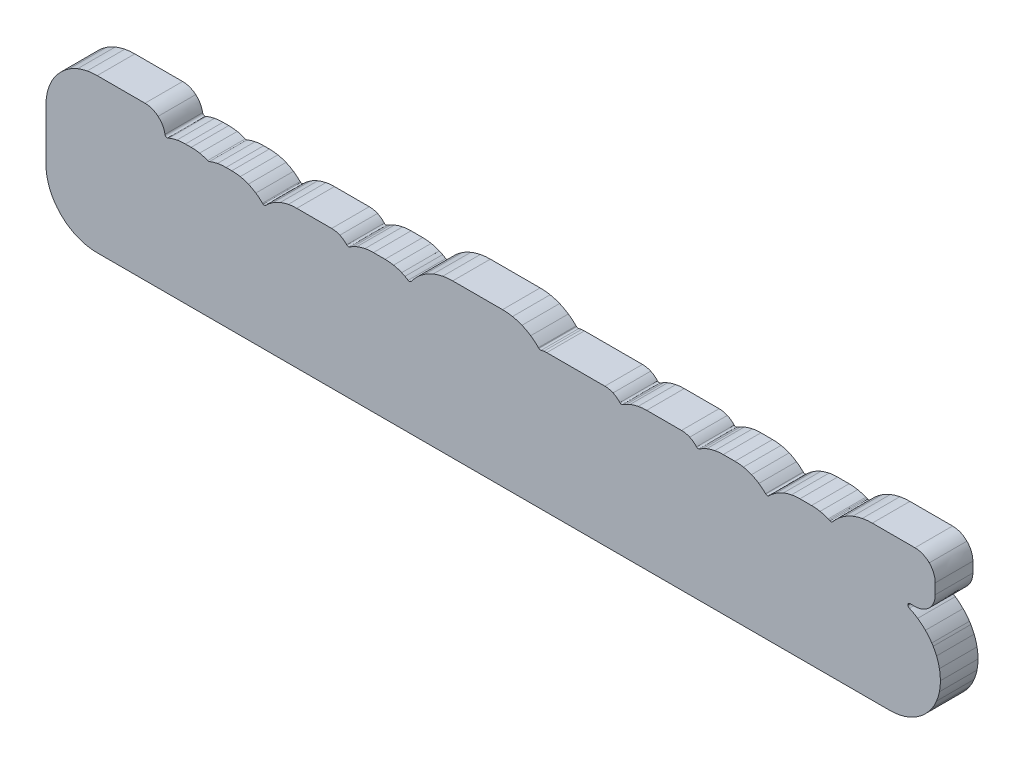
from build123d import *

# Parameters (mm, degrees)
RESSALTO_EXTRUS_O2_DEPTH = 30


with BuildPart() as part:
    # Esboço1 → Ressalto-extrusão2 (new body)
    with BuildSketch(Plane.XY):
        with BuildLine():
            Line((-356.462584, 0.418338), (-356.462584, 20.524216))
            add(Edge.make_bspline(
                [(-356.462584, 20.524216), (-356.462584, 23.265384), (-356.207568, 25.931622), (-355.698044, 28.52166)],
                knots=[0.015384615, 0.015384615, 0.015384615, 0.015384615, 0.023076923, 0.023076923, 0.023076923, 0.023076923], degree=3))
            add(Edge.make_bspline(
                [(-355.698044, 28.52166), (-355.187504, 31.11627), (-354.422456, 33.640776), (-353.404678, 36.092638)],
                knots=[0.023076923, 0.023076923, 0.023076923, 0.023076923, 0.030769231, 0.030769231, 0.030769231, 0.030769231], degree=3))
            add(Edge.make_bspline(
                [(-353.404678, 36.092638), (-352.383852, 38.551104), (-351.136966, 40.874188), (-349.666052, 43.059858)],
                knots=[0.030769231, 0.030769231, 0.030769231, 0.030769231, 0.038461538, 0.038461538, 0.038461538, 0.038461538], degree=3))
            add(Edge.make_bspline(
                [(-349.666052, 43.059858), (-348.202504, 45.23486), (-346.49537, 47.297848), (-344.545412, 49.247552)],
                knots=[0.038461538, 0.038461538, 0.038461538, 0.038461538, 0.046153846, 0.046153846, 0.046153846, 0.046153846], degree=3))
            add(Edge.make_bspline(
                [(-344.545412, 49.247552), (-342.608154, 51.18481), (-340.540848, 52.887626), (-338.346034, 54.352952)],
                knots=[0.046153846, 0.046153846, 0.046153846, 0.046153846, 0.053846154, 0.053846154, 0.053846154, 0.053846154], degree=3))
            add(Edge.make_bspline(
                [(-338.346034, 54.352952), (-336.138266, 55.827168), (-333.785972, 57.078626), (-331.29093, 58.10631)],
                knots=[0.053846154, 0.053846154, 0.053846154, 0.053846154, 0.061538462, 0.061538462, 0.061538462, 0.061538462], degree=3))
            add(Edge.make_bspline(
                [(-331.29093, 58.10631), (-328.822558, 59.12231), (-326.28205, 59.887104), (-323.669914, 60.39993)],
                knots=[0.061538462, 0.061538462, 0.061538462, 0.061538462, 0.069230769, 0.069230769, 0.069230769, 0.069230769], degree=3))
            add(Edge.make_bspline(
                [(-323.669914, 60.39993), (-321.074034, 60.9092), (-318.408812, 61.164216), (-315.676534, 61.164216)],
                knots=[0.069230769, 0.069230769, 0.069230769, 0.069230769, 0.076923077, 0.076923077, 0.076923077, 0.076923077], degree=3))
            Line((-315.676534, 61.164216), (-277.5585, 61.164216))
            add(Edge.make_bspline(
                [(-277.5585, 61.164216), (-273.569938, 61.164216), (-269.919958, 59.721496), (-267.104114, 57.33161)],
                knots=[0.084615385, 0.084615385, 0.084615385, 0.084615385, 0.092307692, 0.092307692, 0.092307692, 0.092307692], degree=3))
            add(Edge.make_bspline(
                [(-267.104114, 57.33161), (-264.243566, 54.903116), (-262.238744, 51.496468), (-261.608824, 47.631604)],
                knots=[0.092307692, 0.092307692, 0.092307692, 0.092307692, 0.1, 0.1, 0.1, 0.1], degree=3))
            add(Edge.make_bspline(
                [(-261.608824, 47.631604), (-261.450074, 46.655736), (-260.529832, 45.993304), (-259.553964, 46.1518)],
                knots=[0.1, 0.1, 0.1, 0.1, 0.107692308, 0.107692308, 0.107692308, 0.107692308], degree=3))
            add(Edge.make_bspline(
                [(-259.553964, 46.1518), (-259.377688, 46.180756), (-259.211826, 46.234604), (-259.059172, 46.308518)],
                knots=[0.107692308, 0.107692308, 0.107692308, 0.107692308, 0.115384615, 0.115384615, 0.115384615, 0.115384615], degree=3))
            Line((-259.059172, 46.308518), (-258.606036, 46.499272))
            add(Edge.make_bspline(
                [(-258.606036, 46.499272), (-256.500376, 47.367952), (-254.33782, 48.021748), (-252.121162, 48.460152)],
                knots=[0.130769231, 0.130769231, 0.130769231, 0.130769231, 0.138461538, 0.138461538, 0.138461538, 0.138461538], degree=3))
            add(Edge.make_bspline(
                [(-252.121162, 48.460152), (-249.917966, 48.895762), (-247.661684, 49.113948), (-245.35384, 49.113948)],
                knots=[0.138461538, 0.138461538, 0.138461538, 0.138461538, 0.146153846, 0.146153846, 0.146153846, 0.146153846], degree=3))
            Line((-245.35384, 49.113948), (-240.773966, 49.113948))
            add(Edge.make_bspline(
                [(-240.773966, 49.113948), (-238.46282, 49.113948), (-236.21111, 48.899318), (-234.019852, 48.470566)],
                knots=[0.153846154, 0.153846154, 0.153846154, 0.153846154, 0.161538462, 0.161538462, 0.161538462, 0.161538462], degree=3))
            add(Edge.make_bspline(
                [(-234.019852, 48.470566), (-231.811068, 48.038766), (-229.664768, 47.394622), (-227.584508, 46.54042)],
                knots=[0.161538462, 0.161538462, 0.161538462, 0.161538462, 0.169230769, 0.169230769, 0.169230769, 0.169230769], degree=3))
            add(Edge.make_bspline(
                [(-227.584508, 46.54042), (-227.13061, 46.353984), (-226.644708, 46.3677), (-226.22383, 46.54042)],
                knots=[0.169230769, 0.169230769, 0.169230769, 0.169230769, 0.176923077, 0.176923077, 0.176923077, 0.176923077], degree=3))
            add(Edge.make_bspline(
                [(-226.22383, 46.54042), (-224.150682, 47.3964), (-222.009462, 48.040544), (-219.801694, 48.470566)],
                knots=[0.176923077, 0.176923077, 0.176923077, 0.176923077, 0.184615385, 0.184615385, 0.184615385, 0.184615385], degree=3))
            add(Edge.make_bspline(
                [(-219.801694, 48.470566), (-217.602308, 48.899318), (-215.3285, 49.113948), (-212.983064, 49.113948)],
                knots=[0.184615385, 0.184615385, 0.184615385, 0.184615385, 0.192307692, 0.192307692, 0.192307692, 0.192307692], degree=3))
            Line((-212.983064, 49.113948), (-208.402936, 49.113948))
            add(Edge.make_bspline(
                [(-208.402936, 49.113948), (-206.094838, 49.113948), (-203.83881, 48.895762), (-201.63536, 48.460152)],
                knots=[0.2, 0.2, 0.2, 0.2, 0.207692308, 0.207692308, 0.207692308, 0.207692308], degree=3))
            add(Edge.make_bspline(
                [(-201.63536, 48.460152), (-199.418702, 48.021748), (-197.256654, 47.367698), (-195.151248, 46.498764)],
                knots=[0.207692308, 0.207692308, 0.207692308, 0.207692308, 0.215384615, 0.215384615, 0.215384615, 0.215384615], degree=3))
            add(Edge.make_bspline(
                [(-195.151248, 46.498764), (-193.063368, 45.636942), (-191.080644, 44.57573), (-189.204854, 43.316398)],
                knots=[0.215384615, 0.215384615, 0.215384615, 0.215384615, 0.223076923, 0.223076923, 0.223076923, 0.223076923], degree=3))
            add(Edge.make_bspline(
                [(-189.204854, 43.316398), (-187.331096, 42.057828), (-185.560462, 40.596566), (-183.892952, 38.932866)],
                knots=[0.223076923, 0.223076923, 0.223076923, 0.223076923, 0.230769231, 0.230769231, 0.230769231, 0.230769231], degree=3))
            add(Edge.make_bspline(
                [(-183.892952, 38.932866), (-183.740044, 38.780974), (-183.566562, 38.662102), (-183.38165, 38.576758)],
                knots=[0.230769231, 0.230769231, 0.230769231, 0.230769231, 0.238461538, 0.238461538, 0.238461538, 0.238461538], degree=3))
            add(Edge.make_bspline(
                [(-183.38165, 38.576758), (-182.698644, 38.181026), (-181.809136, 38.274244), (-181.222904, 38.857428)],
                knots=[0.238461538, 0.238461538, 0.238461538, 0.238461538, 0.246153846, 0.246153846, 0.246153846, 0.246153846], degree=3))
            Line((-181.222904, 38.857428), (-181.216046, 38.864286))
            Line((-181.216046, 38.864286), (-181.109112, 38.97122))
            Line((-181.109112, 38.97122), (-181.10581, 38.967918))
            add(Edge.make_bspline(
                [(-181.10581, 38.967918), (-179.469796, 40.604186), (-177.717196, 42.044874), (-175.850296, 43.289474)],
                knots=[0.269230769, 0.269230769, 0.269230769, 0.269230769, 0.276923077, 0.276923077, 0.276923077, 0.276923077], degree=3))
            Line((-175.850296, 43.289474), (-175.784002, 43.335702))
            add(Edge.make_bspline(
                [(-175.784002, 43.335702), (-173.921674, 44.572174), (-171.932092, 45.626782), (-169.818558, 46.498764)],
                knots=[0.284615385, 0.284615385, 0.284615385, 0.284615385, 0.292307692, 0.292307692, 0.292307692, 0.292307692], degree=3))
            add(Edge.make_bspline(
                [(-169.818558, 46.498764), (-167.712898, 47.367698), (-165.55085, 48.021748), (-163.333938, 48.460152)],
                knots=[0.292307692, 0.292307692, 0.292307692, 0.292307692, 0.3, 0.3, 0.3, 0.3], degree=3))
            add(Edge.make_bspline(
                [(-163.333938, 48.460152), (-161.130742, 48.895762), (-158.874968, 49.113948), (-156.56687, 49.113948)],
                knots=[0.3, 0.3, 0.3, 0.3, 0.307692308, 0.307692308, 0.307692308, 0.307692308], degree=3))
            Line((-156.56687, 49.113948), (-128.775206, 49.113948))
            add(Edge.make_bspline(
                [(-128.775206, 49.113948), (-126.42977, 49.113948), (-124.210572, 48.620934), (-122.216164, 47.733712)],
                knots=[0.315384615, 0.315384615, 0.315384615, 0.315384615, 0.323076923, 0.323076923, 0.323076923, 0.323076923], degree=3))
            add(Edge.make_bspline(
                [(-122.216164, 47.733712), (-120.136666, 46.809406), (-118.285514, 45.4533), (-116.77523, 43.779694)],
                knots=[0.323076923, 0.323076923, 0.323076923, 0.323076923, 0.330769231, 0.330769231, 0.330769231, 0.330769231], degree=3))
            add(Edge.make_bspline(
                [(-116.77523, 43.779694), (-116.152676, 43.088306), (-115.113816, 42.99458), (-114.380264, 43.5356)],
                knots=[0.330769231, 0.330769231, 0.330769231, 0.330769231, 0.338461538, 0.338461538, 0.338461538, 0.338461538], degree=3))
            add(Edge.make_bspline(
                [(-114.380264, 43.5356), (-113.514632, 44.096432), (-112.612678, 44.623228), (-111.67745, 45.11421)],
                knots=[0.338461538, 0.338461538, 0.338461538, 0.338461538, 0.346153846, 0.346153846, 0.346153846, 0.346153846], degree=3))
            add(Edge.make_bspline(
                [(-111.67745, 45.11421), (-110.708694, 45.622972), (-109.72165, 46.085252), (-108.719366, 46.498764)],
                knots=[0.346153846, 0.346153846, 0.346153846, 0.346153846, 0.353846154, 0.353846154, 0.353846154, 0.353846154], degree=3))
            add(Edge.make_bspline(
                [(-108.719366, 46.498764), (-106.61396, 47.367698), (-104.451912, 48.021748), (-102.234746, 48.460152)],
                knots=[0.353846154, 0.353846154, 0.353846154, 0.353846154, 0.361538462, 0.361538462, 0.361538462, 0.361538462], degree=3))
            add(Edge.make_bspline(
                [(-102.234746, 48.460152), (-100.031296, 48.895762), (-97.775268, 49.113948), (-95.467678, 49.113948)],
                knots=[0.361538462, 0.361538462, 0.361538462, 0.361538462, 0.369230769, 0.369230769, 0.369230769, 0.369230769], degree=3))
            Line((-95.467678, 49.113948), (-86.203536, 49.113948))
            add(Edge.make_bspline(
                [(-86.203536, 49.113948), (-83.885278, 49.113948), (-81.623408, 48.895762), (-79.418942, 48.460152)],
                knots=[0.376923077, 0.376923077, 0.376923077, 0.376923077, 0.384615385, 0.384615385, 0.384615385, 0.384615385], degree=3))
            add(Edge.make_bspline(
                [(-79.418942, 48.460152), (-77.204824, 48.02251), (-75.048364, 47.368714), (-72.952356, 46.501304)],
                knots=[0.384615385, 0.384615385, 0.384615385, 0.384615385, 0.392307692, 0.392307692, 0.392307692, 0.392307692], degree=3))
            Line((-72.952356, 46.501304), (-72.953372, 46.498764))
            add(Edge.make_bspline(
                [(-72.953372, 46.498764), (-72.027796, 46.115224), (-71.144892, 45.704252), (-70.309486, 45.267372)],
                knots=[0.4, 0.4, 0.4, 0.4, 0.407692308, 0.407692308, 0.407692308, 0.407692308], degree=3))
            add(Edge.make_bspline(
                [(-70.309486, 45.267372), (-69.470778, 44.829222), (-68.626482, 44.337732), (-67.777868, 43.794934)],
                knots=[0.407692308, 0.407692308, 0.407692308, 0.407692308, 0.415384615, 0.415384615, 0.415384615, 0.415384615], degree=3))
            add(Edge.make_bspline(
                [(-67.777868, 43.794934), (-66.974212, 43.27906), (-65.912746, 43.486578), (-65.359788, 44.251118)],
                knots=[0.415384615, 0.415384615, 0.415384615, 0.415384615, 0.423076923, 0.423076923, 0.423076923, 0.423076923], degree=3))
            Line((-65.359788, 44.251118), (-65.358772, 44.250356))
            add(Edge.make_bspline(
                [(-65.358772, 44.250356), (-64.085216, 46.007528), (-62.6491, 47.685706), (-61.051948, 49.283112)],
                knots=[0.430769231, 0.430769231, 0.430769231, 0.430769231, 0.438461538, 0.438461538, 0.438461538, 0.438461538], degree=3))
            add(Edge.make_bspline(
                [(-61.051948, 49.283112), (-59.11977, 51.215036), (-57.059068, 52.912264), (-54.87035, 54.373526)],
                knots=[0.438461538, 0.438461538, 0.438461538, 0.438461538, 0.446153846, 0.446153846, 0.446153846, 0.446153846], degree=3))
            add(Edge.make_bspline(
                [(-54.87035, 54.373526), (-52.669948, 55.842916), (-50.323496, 57.090564), (-47.83582, 58.114946)],
                knots=[0.446153846, 0.446153846, 0.446153846, 0.446153846, 0.453846154, 0.453846154, 0.453846154, 0.453846154], degree=3))
            add(Edge.make_bspline(
                [(-47.83582, 58.114946), (-45.37583, 59.128152), (-42.842434, 59.89066), (-40.23868, 60.401962)],
                knots=[0.453846154, 0.453846154, 0.453846154, 0.453846154, 0.461538462, 0.461538462, 0.461538462, 0.461538462], degree=3))
            add(Edge.make_bspline(
                [(-40.23868, 60.401962), (-37.650674, 60.909962), (-34.99358, 61.164216), (-32.269684, 61.164216)],
                knots=[0.461538462, 0.461538462, 0.461538462, 0.461538462, 0.469230769, 0.469230769, 0.469230769, 0.469230769], degree=3))
            Line((-32.269684, 61.164216), (7.440676, 61.164216))
            add(Edge.make_bspline(
                [(7.440676, 61.164216), (10.173208, 61.164216), (12.831572, 60.909962), (15.413228, 60.401962)],
                knots=[0.476923077, 0.476923077, 0.476923077, 0.476923077, 0.484615385, 0.484615385, 0.484615385, 0.484615385], degree=3))
            add(Edge.make_bspline(
                [(15.413228, 60.401962), (18.000218, 59.892946), (20.517104, 59.130184), (22.9616, 58.114946)],
                knots=[0.484615385, 0.484615385, 0.484615385, 0.484615385, 0.492307692, 0.492307692, 0.492307692, 0.492307692], degree=3))
            add(Edge.make_bspline(
                [(22.9616, 58.114946), (25.412446, 57.097422), (27.728926, 55.854346), (29.907738, 54.388258)],
                knots=[0.492307692, 0.492307692, 0.492307692, 0.492307692, 0.5, 0.5, 0.5, 0.5], degree=3))
            add(Edge.make_bspline(
                [(29.907738, 54.388258), (32.07639, 52.928774), (34.133282, 51.226974), (36.077144, 49.283112)],
                knots=[0.5, 0.5, 0.5, 0.5, 0.507692308, 0.507692308, 0.507692308, 0.507692308], degree=3))
            add(Edge.make_bspline(
                [(36.077144, 49.283112), (36.1061, 49.253902), (36.136326, 49.225962), (36.166806, 49.199038)],
                knots=[0.507692308, 0.507692308, 0.507692308, 0.507692308, 0.515384615, 0.515384615, 0.515384615, 0.515384615], degree=3))
            Line((36.166806, 49.199038), (36.420044, 48.943514))
            add(Edge.make_bspline(
                [(36.420044, 48.943514), (36.914836, 48.445674), (37.629846, 48.300132), (38.253924, 48.506888)],
                knots=[0.523076923, 0.523076923, 0.523076923, 0.523076923, 0.530769231, 0.530769231, 0.530769231, 0.530769231], degree=3))
            add(Edge.make_bspline(
                [(38.253924, 48.506888), (38.942518, 48.702468), (39.659814, 48.85436), (40.400986, 48.958754)],
                knots=[0.530769231, 0.530769231, 0.530769231, 0.530769231, 0.538461538, 0.538461538, 0.538461538, 0.538461538], degree=3))
            add(Edge.make_bspline(
                [(40.400986, 48.958754), (41.127172, 49.060862), (41.888918, 49.113948), (42.68216, 49.113948)],
                knots=[0.538461538, 0.538461538, 0.538461538, 0.538461538, 0.546153846, 0.546153846, 0.546153846, 0.546153846], degree=3))
            Line((42.68216, 49.113948), (89.001092, 49.113948))
            add(Edge.make_bspline(
                [(89.001092, 49.113948), (91.346782, 49.113948), (93.566234, 48.62068), (95.560388, 47.733712)],
                knots=[0.553846154, 0.553846154, 0.553846154, 0.553846154, 0.561538462, 0.561538462, 0.561538462, 0.561538462], degree=3))
            add(Edge.make_bspline(
                [(95.560388, 47.733712), (97.639886, 46.808898), (99.491038, 45.452792), (101.001068, 43.77944)],
                knots=[0.561538462, 0.561538462, 0.561538462, 0.561538462, 0.569230769, 0.569230769, 0.569230769, 0.569230769], degree=3))
            add(Edge.make_bspline(
                [(101.001068, 43.77944), (101.623622, 43.088052), (102.662736, 42.994326), (103.396288, 43.535346)],
                knots=[0.569230769, 0.569230769, 0.569230769, 0.569230769, 0.576923077, 0.576923077, 0.576923077, 0.576923077], degree=3))
            add(Edge.make_bspline(
                [(103.396288, 43.535346), (104.26192, 44.096178), (105.163874, 44.62272), (106.099102, 45.113956)],
                knots=[0.576923077, 0.576923077, 0.576923077, 0.576923077, 0.584615385, 0.584615385, 0.584615385, 0.584615385], degree=3))
            add(Edge.make_bspline(
                [(106.099102, 45.113956), (107.068112, 45.622718), (108.055156, 46.085252), (109.057948, 46.498764)],
                knots=[0.584615385, 0.584615385, 0.584615385, 0.584615385, 0.592307692, 0.592307692, 0.592307692, 0.592307692], degree=3))
            add(Edge.make_bspline(
                [(109.057948, 46.498764), (111.163354, 47.367698), (113.325402, 48.021748), (115.542314, 48.460152)],
                knots=[0.592307692, 0.592307692, 0.592307692, 0.592307692, 0.6, 0.6, 0.6, 0.6], degree=3))
            add(Edge.make_bspline(
                [(115.542314, 48.460152), (117.74551, 48.895762), (120.001538, 49.113948), (122.309382, 49.113948)],
                knots=[0.6, 0.6, 0.6, 0.6, 0.607692308, 0.607692308, 0.607692308, 0.607692308], degree=3))
            Line((122.309382, 49.113948), (150.100538, 49.113948))
            add(Edge.make_bspline(
                [(150.100538, 49.113948), (152.446482, 49.113948), (154.665934, 48.62068), (156.660088, 47.733712)],
                knots=[0.615384615, 0.615384615, 0.615384615, 0.615384615, 0.623076923, 0.623076923, 0.623076923, 0.623076923], degree=3))
            add(Edge.make_bspline(
                [(156.660088, 47.733712), (158.739078, 46.808898), (160.590738, 45.452792), (162.100768, 43.779186)],
                knots=[0.623076923, 0.623076923, 0.623076923, 0.623076923, 0.630769231, 0.630769231, 0.630769231, 0.630769231], degree=3))
            add(Edge.make_bspline(
                [(162.100768, 43.779186), (162.723322, 43.087544), (163.762436, 42.993818), (164.495988, 43.534838)],
                knots=[0.630769231, 0.630769231, 0.630769231, 0.630769231, 0.638461538, 0.638461538, 0.638461538, 0.638461538], degree=3))
            add(Edge.make_bspline(
                [(164.495988, 43.534838), (165.361112, 44.095416), (166.263828, 44.622466), (167.198802, 45.113702)],
                knots=[0.638461538, 0.638461538, 0.638461538, 0.638461538, 0.646153846, 0.646153846, 0.646153846, 0.646153846], degree=3))
            add(Edge.make_bspline(
                [(167.198802, 45.113702), (168.168066, 45.622718), (169.154602, 46.084744), (170.157394, 46.498764)],
                knots=[0.646153846, 0.646153846, 0.646153846, 0.646153846, 0.653846154, 0.653846154, 0.653846154, 0.653846154], degree=3))
            add(Edge.make_bspline(
                [(170.157394, 46.498764), (172.263308, 47.367698), (174.425356, 48.021748), (176.642014, 48.460152)],
                knots=[0.653846154, 0.653846154, 0.653846154, 0.653846154, 0.661538462, 0.661538462, 0.661538462, 0.661538462], degree=3))
            add(Edge.make_bspline(
                [(176.642014, 48.460152), (178.845464, 48.895762), (181.101238, 49.113948), (183.409082, 49.113948)],
                knots=[0.661538462, 0.661538462, 0.661538462, 0.661538462, 0.669230769, 0.669230769, 0.669230769, 0.669230769], degree=3))
            Line((183.409082, 49.113948), (192.672462, 49.113948))
            add(Edge.make_bspline(
                [(192.672462, 49.113948), (194.99072, 49.113948), (197.253098, 48.895762), (199.457564, 48.460152)],
                knots=[0.676923077, 0.676923077, 0.676923077, 0.676923077, 0.684615385, 0.684615385, 0.684615385, 0.684615385], degree=3))
            add(Edge.make_bspline(
                [(199.457564, 48.460152), (201.671682, 48.02251), (203.828142, 47.368714), (205.92415, 46.501304)],
                knots=[0.684615385, 0.684615385, 0.684615385, 0.684615385, 0.692307692, 0.692307692, 0.692307692, 0.692307692], degree=3))
            Line((205.92415, 46.501304), (205.92288, 46.498764))
            add(Edge.make_bspline(
                [(205.92288, 46.498764), (207.960468, 45.654214), (209.911442, 44.604178), (211.773516, 43.349418)],
                knots=[0.7, 0.7, 0.7, 0.7, 0.707692308, 0.707692308, 0.707692308, 0.707692308], degree=3))
            add(Edge.make_bspline(
                [(211.773516, 43.349418), (213.648036, 42.086276), (215.422734, 40.625268), (217.095324, 38.967918)],
                knots=[0.707692308, 0.707692308, 0.707692308, 0.707692308, 0.715384615, 0.715384615, 0.715384615, 0.715384615], degree=3))
            Line((217.095324, 38.967918), (217.26779, 38.796468))
            add(Edge.make_bspline(
                [(217.26779, 38.796468), (217.968576, 38.099492), (219.102432, 38.102286), (219.799154, 38.803326)],
                knots=[0.723076923, 0.723076923, 0.723076923, 0.723076923, 0.730769231, 0.730769231, 0.730769231, 0.730769231], degree=3))
            Line((219.799154, 38.803326), (219.96654, 38.97122))
            Line((219.96654, 38.97122), (219.969842, 38.967918))
            add(Edge.make_bspline(
                [(219.969842, 38.967918), (221.608396, 40.606726), (223.360234, 42.047922), (225.22434, 43.291252)],
                knots=[0.746153846, 0.746153846, 0.746153846, 0.746153846, 0.753846154, 0.753846154, 0.753846154, 0.753846154], degree=3))
            Line((225.22434, 43.291252), (225.225356, 43.289728))
            add(Edge.make_bspline(
                [(225.225356, 43.289728), (227.115624, 44.549568), (229.126542, 45.619416), (231.257094, 46.498764)],
                knots=[0.761538462, 0.761538462, 0.761538462, 0.761538462, 0.769230769, 0.769230769, 0.769230769, 0.769230769], degree=3))
            add(Edge.make_bspline(
                [(231.257094, 46.498764), (233.3625, 47.367698), (235.524548, 48.021748), (237.741206, 48.460152)],
                knots=[0.769230769, 0.769230769, 0.769230769, 0.769230769, 0.776923077, 0.776923077, 0.776923077, 0.776923077], degree=3))
            add(Edge.make_bspline(
                [(237.741206, 48.460152), (239.944656, 48.895762), (242.200684, 49.113948), (244.508782, 49.113948)],
                knots=[0.776923077, 0.776923077, 0.776923077, 0.776923077, 0.784615385, 0.784615385, 0.784615385, 0.784615385], degree=3))
            Line((244.508782, 49.113948), (253.772162, 49.113948))
            add(Edge.make_bspline(
                [(253.772162, 49.113948), (256.09042, 49.113948), (258.352544, 48.895762), (260.55701, 48.460152)],
                knots=[0.792307692, 0.792307692, 0.792307692, 0.792307692, 0.8, 0.8, 0.8, 0.8], degree=3))
            add(Edge.make_bspline(
                [(260.55701, 48.460152), (262.773414, 48.022002), (264.931652, 47.367698), (267.029438, 46.498764)],
                knots=[0.8, 0.8, 0.8, 0.8, 0.807692308, 0.807692308, 0.807692308, 0.807692308], degree=3))
            add(Edge.make_bspline(
                [(267.029438, 46.498764), (267.33881, 46.370494), (267.587984, 46.264576), (267.76807, 46.185074)],
                knots=[0.807692308, 0.807692308, 0.807692308, 0.807692308, 0.815384615, 0.815384615, 0.815384615, 0.815384615], degree=3))
            Line((267.76807, 46.185074), (267.770356, 46.183804))
            Line((267.770356, 46.183804), (267.76807, 46.178216))
            add(Edge.make_bspline(
                [(267.76807, 46.178216), (268.047216, 46.054264), (268.291818, 45.942504), (268.499336, 45.844714)],
                knots=[0.830769231, 0.830769231, 0.830769231, 0.830769231, 0.838461538, 0.838461538, 0.838461538, 0.838461538], degree=3))
            add(Edge.make_bspline(
                [(268.499336, 45.844714), (269.289276, 45.471842), (270.214852, 45.727112), (270.71066, 46.40834)],
                knots=[0.838461538, 0.838461538, 0.838461538, 0.838461538, 0.846153846, 0.846153846, 0.846153846, 0.846153846], degree=3))
            add(Edge.make_bspline(
                [(270.71066, 46.40834), (271.07388, 46.843188), (271.483328, 47.309786), (271.93875, 47.808896)],
                knots=[0.846153846, 0.846153846, 0.846153846, 0.846153846, 0.853846154, 0.853846154, 0.853846154, 0.853846154], degree=3))
            add(Edge.make_bspline(
                [(271.93875, 47.808896), (272.353278, 48.263048), (272.813526, 48.743362), (273.31797, 49.247806)],
                knots=[0.853846154, 0.853846154, 0.853846154, 0.853846154, 0.861538462, 0.861538462, 0.861538462, 0.861538462], degree=3))
            add(Edge.make_bspline(
                [(273.31797, 49.247806), (275.255228, 51.185572), (277.322534, 52.888388), (279.517348, 54.353968)],
                knots=[0.861538462, 0.861538462, 0.861538462, 0.861538462, 0.869230769, 0.869230769, 0.869230769, 0.869230769], degree=3))
            add(Edge.make_bspline(
                [(279.517348, 54.353968), (281.725116, 55.82793), (284.07741, 57.079388), (286.57296, 58.107072)],
                knots=[0.869230769, 0.869230769, 0.869230769, 0.869230769, 0.876923077, 0.876923077, 0.876923077, 0.876923077], degree=3))
            add(Edge.make_bspline(
                [(286.57296, 58.107072), (289.041078, 59.122818), (291.582348, 59.887866), (294.19423, 60.400438)],
                knots=[0.876923077, 0.876923077, 0.876923077, 0.876923077, 0.884615385, 0.884615385, 0.884615385, 0.884615385], degree=3))
            add(Edge.make_bspline(
                [(294.19423, 60.400438), (296.790364, 60.909962), (299.45584, 61.164978), (302.188118, 61.164978)],
                knots=[0.884615385, 0.884615385, 0.884615385, 0.884615385, 0.892307692, 0.892307692, 0.892307692, 0.892307692], degree=3))
            Line((302.188118, 61.164978), (336.201258, 61.164978))
            add(Edge.make_bspline(
                [(336.201258, 61.164978), (340.662514, 61.164978), (344.702384, 59.35599), (347.62567, 56.432958)],
                knots=[0.9, 0.9, 0.9, 0.9, 0.907692308, 0.907692308, 0.907692308, 0.907692308], degree=3))
            add(Edge.make_bspline(
                [(347.62567, 56.432958), (350.548956, 53.509672), (352.35769, 49.469802), (352.35769, 45.008292)],
                knots=[0.907692308, 0.907692308, 0.907692308, 0.907692308, 0.915384615, 0.915384615, 0.915384615, 0.915384615], degree=3))
            Line((352.35769, 45.008292), (352.35769, 36.798758))
            add(Edge.make_bspline(
                [(352.35769, 36.798758), (352.35769, 32.337502), (350.548956, 28.297632), (347.62567, 25.374346)],
                knots=[0.923076923, 0.923076923, 0.923076923, 0.923076923, 0.930769231, 0.930769231, 0.930769231, 0.930769231], degree=3))
            add(Edge.make_bspline(
                [(347.62567, 25.374346), (344.702384, 22.45106), (340.662514, 20.642326), (336.201258, 20.642326)],
                knots=[0.930769231, 0.930769231, 0.930769231, 0.930769231, 0.938461538, 0.938461538, 0.938461538, 0.938461538], degree=3))
            Line((336.201258, 20.642326), (332.329282, 20.642326))
            add(Edge.make_bspline(
                [(332.329282, 20.642326), (331.338174, 20.642326), (330.534264, 19.838416), (330.534264, 18.847054)],
                knots=[0.946153846, 0.946153846, 0.946153846, 0.946153846, 0.953846154, 0.953846154, 0.953846154, 0.953846154], degree=3))
            add(Edge.make_bspline(
                [(330.534264, 18.847054), (330.534264, 18.048478), (331.056234, 17.371822), (331.777086, 17.138904)],
                knots=[0.953846154, 0.953846154, 0.953846154, 0.953846154, 0.961538462, 0.961538462, 0.961538462, 0.961538462], degree=3))
            add(Edge.make_bspline(
                [(331.777086, 17.138904), (334.059276, 16.16329), (336.258154, 14.950948), (338.372196, 13.503656)],
                knots=[0.961538462, 0.961538462, 0.961538462, 0.961538462, 0.969230769, 0.969230769, 0.969230769, 0.969230769], degree=3))
            add(Edge.make_bspline(
                [(338.372196, 13.503656), (340.515448, 12.036298), (342.57361, 10.315956), (344.545412, 8.344154)],
                knots=[0.969230769, 0.969230769, 0.969230769, 0.969230769, 0.976923077, 0.976923077, 0.976923077, 0.976923077], degree=3))
            add(Edge.make_bspline(
                [(344.545412, 8.344154), (346.483432, 6.406134), (348.185994, 4.338828), (349.651574, 2.144014)],
                knots=[0.976923077, 0.976923077, 0.976923077, 0.976923077, 0.984615385, 0.984615385, 0.984615385, 0.984615385], degree=3))
            add(Edge.make_bspline(
                [(349.651574, 2.144014), (350.029526, 1.578356), (350.392238, 1.003046), (350.74098, 0.418338)],
                knots=[0.984615385, 0.984615385, 0.984615385, 0.984615385, 1, 1, 1, 1], degree=3))
            add(Edge.make_bspline(
                [(353.404678, -4.910582), (352.637598, -3.052826), (351.752154, -1.27762), (350.74098, 0.418338)],
                knots=[0.9, 0.9, 0.9, 0.9, 0.933333333, 0.933333333, 0.933333333, 0.933333333], degree=3))
            add(Edge.make_bspline(
                [(355.698044, -12.53236), (355.185472, -9.919716), (354.420424, -7.378446), (353.404678, -4.910582)],
                knots=[0.866666667, 0.866666667, 0.866666667, 0.866666667, 0.9, 0.9, 0.9, 0.9], degree=3))
            add(Edge.make_bspline(
                [(356.462584, -20.524978), (356.462584, -17.792954), (356.207314, -15.12824), (355.698044, -12.53236)],
                knots=[0.833333333, 0.833333333, 0.833333333, 0.833333333, 0.866666667, 0.866666667, 0.866666667, 0.866666667], degree=3))
            add(Edge.make_bspline(
                [(355.698044, -28.520644), (356.207314, -25.931368), (356.462584, -23.265384), (356.462584, -20.524978)],
                knots=[0.8, 0.8, 0.8, 0.8, 0.833333333, 0.833333333, 0.833333333, 0.833333333], degree=3))
            add(Edge.make_bspline(
                [(353.404678, -36.092892), (354.422964, -33.640522), (355.187504, -31.115254), (355.698044, -28.520644)],
                knots=[0.766666667, 0.766666667, 0.766666667, 0.766666667, 0.8, 0.8, 0.8, 0.8], degree=3))
            add(Edge.make_bspline(
                [(349.666306, -43.059604), (351.13722, -40.873934), (352.383852, -38.55085), (353.404678, -36.092892)],
                knots=[0.733333333, 0.733333333, 0.733333333, 0.733333333, 0.766666667, 0.766666667, 0.766666667, 0.766666667], degree=3))
            add(Edge.make_bspline(
                [(344.545412, -49.24806), (346.494608, -47.298356), (348.202504, -45.235114), (349.666306, -43.059604)],
                knots=[0.7, 0.7, 0.7, 0.7, 0.733333333, 0.733333333, 0.733333333, 0.733333333], degree=3))
            add(Edge.make_bspline(
                [(338.358226, -54.368446), (340.533228, -52.904644), (342.596724, -51.197256), (344.545412, -49.24806)],
                knots=[0.666666667, 0.666666667, 0.666666667, 0.666666667, 0.7, 0.7, 0.7, 0.7], degree=3))
            add(Edge.make_bspline(
                [(331.390498, -58.107072), (333.84871, -57.0865), (336.172048, -55.839868), (338.358226, -54.368446)],
                knots=[0.633333333, 0.633333333, 0.633333333, 0.633333333, 0.666666667, 0.666666667, 0.666666667, 0.666666667], degree=3))
            add(Edge.make_bspline(
                [(323.81952, -60.400692), (326.413876, -59.890152), (328.938382, -59.125358), (331.390498, -58.107072)],
                knots=[0.6, 0.6, 0.6, 0.6, 0.633333333, 0.633333333, 0.633333333, 0.633333333], degree=3))
            add(Edge.make_bspline(
                [(315.822076, -61.164978), (318.563244, -61.164978), (321.229482, -60.909962), (323.81952, -60.400692)],
                knots=[0.566666667, 0.566666667, 0.566666667, 0.566666667, 0.6, 0.6, 0.6, 0.6], degree=3))
            Line((315.822076, -61.164978), (281.66314, -61.164978))
            Line((281.66314, -61.164978), (28.934918, -61.164978))
            Line((28.934918, -61.164978), (5.552186, -61.164978))
            Line((5.552186, -61.164978), (-30.381448, -61.164978))
            Line((-30.381448, -61.164978), (-49.876964, -61.164978))
            Line((-49.876964, -61.164978), (-277.5585, -61.164978))
            Line((-277.5585, -61.164978), (-289.804348, -61.164978))
            Line((-289.804348, -61.164978), (-315.676534, -61.164978))
            add(Edge.make_bspline(
                [(-323.669152, -60.400692), (-321.073272, -60.909708), (-318.408558, -61.164978), (-315.676534, -61.164978)],
                knots=[0.266666667, 0.266666667, 0.266666667, 0.266666667, 0.3, 0.3, 0.3, 0.3], degree=3))
            add(Edge.make_bspline(
                [(-331.290676, -58.107072), (-328.822304, -59.123072), (-326.281542, -59.887866), (-323.669152, -60.400692)],
                knots=[0.233333333, 0.233333333, 0.233333333, 0.233333333, 0.266666667, 0.266666667, 0.266666667, 0.266666667], degree=3))
            add(Edge.make_bspline(
                [(-338.345272, -54.354222), (-336.138012, -55.828438), (-333.785464, -57.079642), (-331.290676, -58.107072)],
                knots=[0.2, 0.2, 0.2, 0.2, 0.233333333, 0.233333333, 0.233333333, 0.233333333], degree=3))
            add(Edge.make_bspline(
                [(-344.545412, -49.24806), (-342.607392, -51.18608), (-340.540086, -52.888642), (-338.345272, -54.354222)],
                knots=[0.166666667, 0.166666667, 0.166666667, 0.166666667, 0.2, 0.2, 0.2, 0.2], degree=3))
            add(Edge.make_bspline(
                [(-349.666052, -43.06062), (-348.20225, -45.235876), (-346.494608, -47.299118), (-344.545412, -49.24806)],
                knots=[0.133333333, 0.133333333, 0.133333333, 0.133333333, 0.166666667, 0.166666667, 0.166666667, 0.166666667], degree=3))
            add(Edge.make_bspline(
                [(-353.404678, -36.092892), (-352.383852, -38.551358), (-351.13722, -40.874696), (-349.666052, -43.06062)],
                knots=[0.1, 0.1, 0.1, 0.1, 0.133333333, 0.133333333, 0.133333333, 0.133333333], degree=3))
            add(Edge.make_bspline(
                [(-355.698044, -28.521914), (-355.187504, -31.116524), (-354.42271, -33.640776), (-353.404678, -36.092892)],
                knots=[0.066666667, 0.066666667, 0.066666667, 0.066666667, 0.1, 0.1, 0.1, 0.1], degree=3))
            add(Edge.make_bspline(
                [(-356.462584, -20.524978), (-356.462584, -23.266146), (-356.207568, -25.932384), (-355.698044, -28.521914)],
                knots=[0.033333333, 0.033333333, 0.033333333, 0.033333333, 0.066666667, 0.066666667, 0.066666667, 0.066666667], degree=3))
            Line((-356.462584, -20.524978), (-356.462584, 0.418338))
        make_face()
    extrude(amount=RESSALTO_EXTRUS_O2_DEPTH)


solid = part.part
